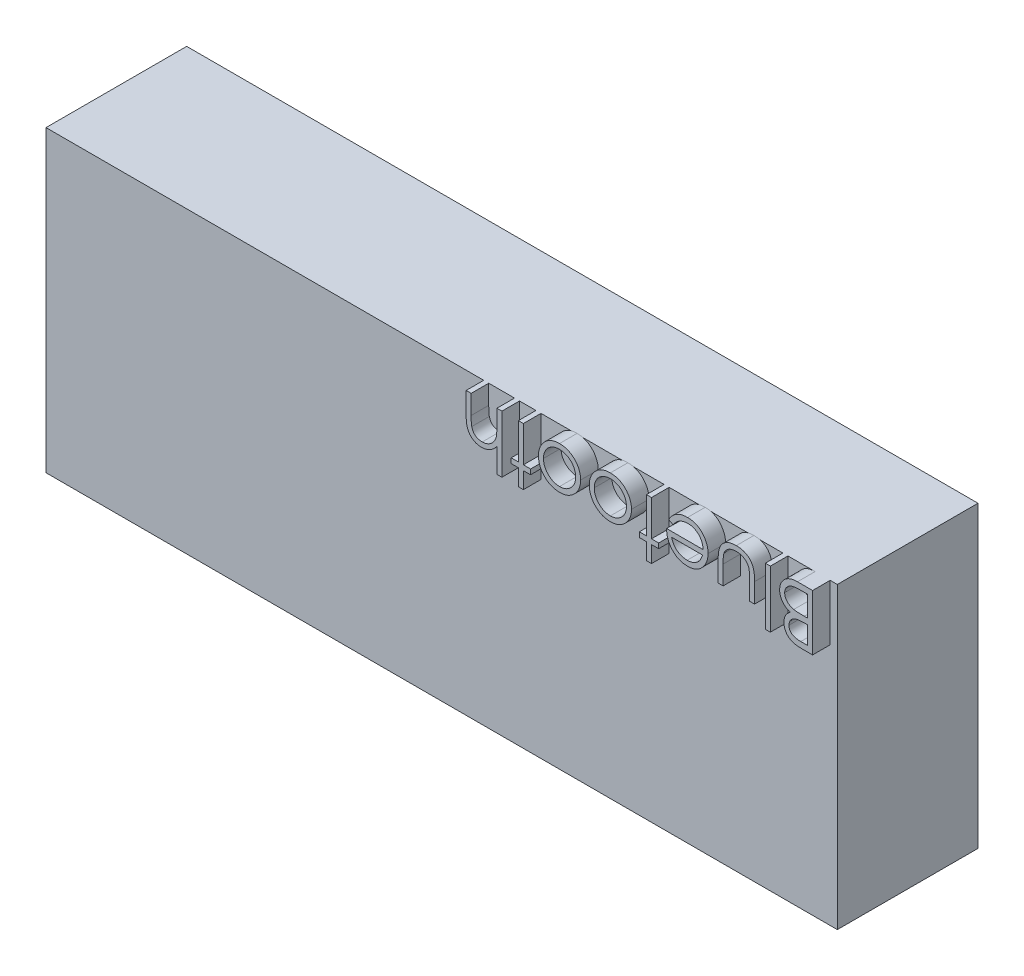
from build123d import *

# Parameters (mm, degrees)
SKETCH1_W           = 45
SKETCH1_H           = 17
BOSS_EXTRUDE1_DEPTH = 8
SKETCH2_W           = 0.284935898
SKETCH2_H           = 3.256410256
BOSS_EXTRUDE2_DEPTH = 1


with BuildPart() as part:
    # Sketch1 → Boss-Extrude1 (new body)
    with BuildSketch(Plane.XY):
        with Locations((-22.5, 8.5)):
            Rectangle(SKETCH1_W, SKETCH1_H)
    extrude(amount=BOSS_EXTRUDE1_DEPTH)

    # Sketch2 → Boss-Extrude2 (add)
    with BuildSketch(Plane.XY.offset(8)):
        with BuildLine():
            Line((-0.407051282, 13.825), (-1.026532452, 13.825))
            add(Edge.make_bspline(
                [(-1.026532452, 13.825), (-1.056857335, 13.825156921), (-1.115634507, 13.825461072), (-1.201098501, 13.830287737), (-1.281175294, 13.836704332), (-1.35572338, 13.847467824), (-1.425227832, 13.858628146), (-1.488983034, 13.875008826), (-1.547523015, 13.893101885), (-1.617817551, 13.92094051), (-1.697576333, 13.964174247), (-1.7833021, 14.028293986), (-1.857820167, 14.105168377), (-1.921182613, 14.192772808), (-1.972032324, 14.28914761), (-2.008354446, 14.392219247), (-2.03168916, 14.500253662), (-2.034058822, 14.574321243), (-2.03525641, 14.611753806)],
                knots=[0, 0, 0, 0, 9.0959e-05, 0.000176302, 0.000256745, 0.000331852, 0.000402223, 0.000467782, 0.000529134, 0.000585943, 0.000694367, 0.0008002, 0.000905896, 0.001014288, 0.001123535, 0.001231562, 0.00134133, 0.001453488, 0.001453488, 0.001453488, 0.001453488], degree=3))
            add(Edge.make_bspline(
                [(-2.03525641, 14.611753806), (-2.034278203, 14.646821674), (-2.032355933, 14.715733341), (-2.013576913, 14.816186738), (-1.985230438, 14.912110727), (-1.944324752, 15.002580893), (-1.892166566, 15.086802276), (-1.828708295, 15.163338275), (-1.753464177, 15.230686236), (-1.696970478, 15.268166335), (-1.668274239, 15.287204527)],
                knots=[0, 0, 0, 0, 0.000105099, 0.000206529, 0.000305524, 0.000404587, 0.000503422, 0.000601875, 0.000701862, 0.000805081, 0.000805081, 0.000805081, 0.000805081], degree=3))
            add(Edge.make_bspline(
                [(-1.668274239, 15.287204527), (-1.704345186, 15.301045853), (-1.773357845, 15.327527739), (-1.868451073, 15.37452874), (-1.950407983, 15.425257679), (-2.020284774, 15.480086384), (-2.078836588, 15.540805168), (-2.130996895, 15.605814962), (-2.175263744, 15.677379834), (-2.213033242, 15.753949009), (-2.242952687, 15.835117005), (-2.263720941, 15.920276589), (-2.276892235, 16.00846321), (-2.278614621, 16.068399436), (-2.279487179, 16.098763021)],
                knots=[0, 0, 0, 0, 0.000115862, 0.000221672, 0.000317675, 0.000404589, 0.000487344, 0.000570185, 0.000654188, 0.000739236, 0.000825961, 0.000913116, 0.001001804, 0.001092863, 0.001092863, 0.001092863, 0.001092863], degree=3))
            add(Edge.make_bspline(
                [(-2.279487179, 16.098763021), (-2.278600956, 16.129757203), (-2.276857285, 16.190739126), (-2.26399524, 16.280324877), (-2.242211085, 16.365933729), (-2.212227258, 16.448135531), (-2.17314183, 16.526448851), (-2.12592257, 16.601489144), (-2.0692495, 16.672144303), (-2.005430049, 16.73943962), (-1.934225902, 16.80097828), (-1.855764504, 16.853862582), (-1.772056737, 16.899540927), (-1.681956325, 16.936263754), (-1.586102591, 16.965011011), (-1.484473079, 16.984886817), (-1.3771255, 16.998332925), (-1.303455585, 16.999434879), (-1.26567508, 17)],
                knots=[0, 0, 0, 0, 9.2965e-05, 0.000182912, 0.000270839, 0.000357564, 0.000444886, 0.000532935, 0.000623027, 0.000716149, 0.000810866, 0.000904715, 0.000999484, 0.001096453, 0.001196056, 0.001299211, 0.001406816, 0.001520092, 0.001520092, 0.001520092, 0.001520092], degree=3))
            Line((-1.26567508, 17), (-0.407051282, 17))
            Line((-0.407051282, 17), (-0.407051282, 13.825))
        make_face()
        with BuildLine():
            Line((-0.691987179, 14.150641026), (-0.691987179, 15.168269231))
            Line((-0.691987179, 15.168269231), (-0.883428486, 15.168269231))
            add(Edge.make_bspline(
                [(-0.883428486, 15.168269231), (-0.911413002, 15.167909462), (-0.965484791, 15.167214317), (-1.043997361, 15.165160292), (-1.11669336, 15.159660798), (-1.18382327, 15.153844164), (-1.244937207, 15.144887778), (-1.300239597, 15.13392756), (-1.350227775, 15.122437825), (-1.407847206, 15.102841292), (-1.473197521, 15.074182831), (-1.542375043, 15.028618136), (-1.604637922, 14.975864071), (-1.656001204, 14.913289506), (-1.698763, 14.845714635), (-1.727552857, 14.772635549), (-1.747626216, 14.696570575), (-1.749413214, 14.644112234), (-1.750320513, 14.617477965)],
                knots=[0, 0, 0, 0, 8.3964e-05, 0.000162235, 0.000235554, 0.000302638, 0.000364342, 0.000420722, 0.000471782, 0.000518041, 0.000603156, 0.000685012, 0.000765726, 0.000846997, 0.000926956, 0.001004553, 0.001081836, 0.001161544, 0.001161544, 0.001161544, 0.001161544], degree=3))
            add(Edge.make_bspline(
                [(-1.750320513, 14.617477965), (-1.749878009, 14.599845497), (-1.749009988, 14.565257486), (-1.740826818, 14.514864741), (-1.72953414, 14.466910763), (-1.710909702, 14.422688306), (-1.688844556, 14.380644538), (-1.66056231, 14.342107543), (-1.627950279, 14.306033348), (-1.589928737, 14.273388889), (-1.54665311, 14.24386386), (-1.496752527, 14.219285683), (-1.441583665, 14.197443357), (-1.379996079, 14.180886362), (-1.313216539, 14.166512255), (-1.240226225, 14.157448022), (-1.161465028, 14.151625016), (-1.106894398, 14.150976338), (-1.078685897, 14.150641026)],
                knots=[0, 0, 0, 0, 5.2851e-05, 0.000103672, 0.000152881, 0.000200242, 0.000247195, 0.000295032, 0.000343206, 0.000392807, 0.000445022, 0.000499919, 0.000559328, 0.000622755, 0.000690987, 0.000764118, 0.000843191, 0.000927803, 0.000927803, 0.000927803, 0.000927803], degree=3))
            Line((-1.078685897, 14.150641026), (-0.691987179, 14.150641026))
        make_face(mode=Mode.SUBTRACT)
        with BuildLine():
            Line((-0.691987179, 15.493910256), (-0.691987179, 16.674358974))
            Line((-0.691987179, 16.674358974), (-1.097766426, 16.674358974))
            add(Edge.make_bspline(
                [(-1.097766426, 16.674358974), (-1.126809263, 16.673977387), (-1.182785501, 16.673241928), (-1.263667057, 16.671496784), (-1.338233662, 16.665022306), (-1.40710616, 16.658814977), (-1.469965885, 16.648674015), (-1.527424255, 16.638854064), (-1.578168894, 16.624403522), (-1.637543053, 16.60451932), (-1.703952452, 16.57274173), (-1.77647465, 16.526010062), (-1.84035162, 16.469087446), (-1.894546754, 16.403544285), (-1.939607631, 16.333014359), (-1.97078086, 16.257358853), (-1.990979337, 16.179104783), (-1.993358237, 16.12559752), (-1.994551282, 16.098763021)],
                knots=[0, 0, 0, 0, 8.7144e-05, 0.000167958, 0.000242592, 0.000311637, 0.000375322, 0.000433575, 0.000486346, 0.000533411, 0.000621324, 0.000706353, 0.000791497, 0.000876839, 0.000960842, 0.001041518, 0.001121424, 0.001201814, 0.001201814, 0.001201814, 0.001201814], degree=3))
            add(Edge.make_bspline(
                [(-1.994551282, 16.098763021), (-1.994307745, 16.081984403), (-1.993824599, 16.048697807), (-1.986230025, 15.999825141), (-1.975690698, 15.952248989), (-1.960158691, 15.906615593), (-1.941369185, 15.862139153), (-1.916581041, 15.820266851), (-1.888620197, 15.77921625), (-1.845313079, 15.726707986), (-1.781463528, 15.666939881), (-1.690699138, 15.609154389), (-1.588073896, 15.561797377), (-1.513465598, 15.541777202), (-1.47492488, 15.531435296)],
                knots=[0, 0, 0, 0, 5.0282e-05, 9.9752e-05, 0.000148043, 0.000196314, 0.000244168, 0.000292605, 0.000342002, 0.000393062, 0.000496563, 0.000602763, 0.000714617, 0.000834141, 0.000834141, 0.000834141, 0.000834141], degree=3))
            add(Edge.make_bspline(
                [(-1.47492488, 15.531435296), (-1.459477072, 15.528300831), (-1.425983037, 15.521504664), (-1.371365883, 15.514335298), (-1.308803548, 15.507904144), (-1.238563435, 15.503271916), (-1.16036619, 15.498299301), (-1.074236934, 15.496434267), (-0.980114777, 15.494157894), (-0.914807331, 15.493994914), (-0.880884415, 15.493910256)],
                knots=[0, 0, 0, 0, 4.7275e-05, 0.000102503, 0.000165156, 0.000235937, 0.000313659, 0.000400195, 0.000494345, 0.00059611, 0.00059611, 0.00059611, 0.00059611], degree=3))
            Line((-0.880884415, 15.493910256), (-0.691987179, 15.493910256))
        make_face(mode=Mode.SUBTRACT)
        with Locations((-2.951121795, 15.371794872)):
            Rectangle(SKETCH2_W, SKETCH2_H)
        with BuildLine():
            Line((-3.704166667, 14.679807692), (-3.989102564, 14.679807692))
            Line((-3.989102564, 14.679807692), (-3.989102564, 15.755949519))
            add(Edge.make_bspline(
                [(-3.989102564, 15.755949519), (-3.989231292, 15.787538727), (-3.989477543, 15.847967403), (-3.991147539, 15.934921751), (-3.995075553, 16.014221197), (-3.999986665, 16.085911552), (-4.006302317, 16.149980685), (-4.013816508, 16.206204816), (-4.022215219, 16.25522154), (-4.030436396, 16.284743013), (-4.034259816, 16.298472556)],
                knots=[0, 0, 0, 0, 9.4769e-05, 0.000181288, 0.000260882, 0.000332932, 0.000396851, 0.000453969, 0.000503119, 0.000545851, 0.000545851, 0.000545851, 0.000545851], degree=3))
            add(Edge.make_bspline(
                [(-4.034259816, 16.298472556), (-4.040393462, 16.31572897), (-4.052533236, 16.34988304), (-4.074552169, 16.399222336), (-4.101794336, 16.444917315), (-4.131594817, 16.488745657), (-4.166005522, 16.529350994), (-4.204523306, 16.566998531), (-4.246464485, 16.602127441), (-4.307900009, 16.644495716), (-4.391883133, 16.6893331), (-4.501898386, 16.728560205), (-4.621403134, 16.751659143), (-4.704096103, 16.75437388), (-4.746599559, 16.755769231)],
                knots=[0, 0, 0, 0, 5.4937e-05, 0.000108733, 0.000161748, 0.000214322, 0.000267581, 0.000321101, 0.000375743, 0.000431495, 0.000544744, 0.000660216, 0.00078071, 0.000908143, 0.000908143, 0.000908143, 0.000908143], degree=3))
            add(Edge.make_bspline(
                [(-4.746599559, 16.755769231), (-4.789108401, 16.754379092), (-4.871146739, 16.751696245), (-4.989402837, 16.728908955), (-5.097702195, 16.691733369), (-5.194780318, 16.639112717), (-5.280027791, 16.574961308), (-5.351059294, 16.499654919), (-5.409667762, 16.415610109), (-5.435257675, 16.352904324), (-5.448127003, 16.321369191)],
                knots=[0, 0, 0, 0, 0.000127432, 0.000245933, 0.000359782, 0.000469627, 0.000575844, 0.000678419, 0.000779147, 0.000881052, 0.000881052, 0.000881052, 0.000881052], degree=3))
            add(Edge.make_bspline(
                [(-5.448127003, 16.321369191), (-5.451934583, 16.308700032), (-5.460352214, 16.280691616), (-5.469331583, 16.233170163), (-5.477755141, 16.176554224), (-5.483371043, 16.110249231), (-5.489780513, 16.034839887), (-5.49199372, 15.949936218), (-5.495154294, 15.856038678), (-5.495179262, 15.790298426), (-5.495192308, 15.755949519)],
                knots=[0, 0, 0, 0, 3.9663e-05, 8.7686e-05, 0.000144892, 0.000211343, 0.000287245, 0.000371895, 0.00046606, 0.000569097, 0.000569097, 0.000569097, 0.000569097], degree=3))
            Line((-5.495192308, 15.755949519), (-5.495192308, 14.679807692))
            Line((-5.495192308, 14.679807692), (-5.780128205, 14.679807692))
            Line((-5.780128205, 14.679807692), (-5.780128205, 15.809375))
            add(Edge.make_bspline(
                [(-5.780128205, 15.809375), (-5.779726086, 15.847753435), (-5.77894592, 15.922212849), (-5.773969544, 16.03042348), (-5.765312185, 16.131462913), (-5.752510961, 16.225021849), (-5.73698131, 16.311122661), (-5.717343925, 16.389792441), (-5.693771382, 16.4611406), (-5.667172133, 16.526208158), (-5.635826264, 16.585259918), (-5.602259332, 16.640993122), (-5.5645166, 16.693224037), (-5.52335272, 16.742430516), (-5.477576262, 16.787418474), (-5.429577707, 16.830494553), (-5.377013169, 16.869001248), (-5.321654085, 16.904989796), (-5.262104821, 16.936927143), (-5.198877564, 16.964561638), (-5.1320392, 16.988571347), (-5.061485337, 17.007124819), (-4.987257349, 17.022777708), (-4.909450013, 17.033196025), (-4.827915259, 17.039848013), (-4.772478131, 17.040414626), (-4.744055489, 17.040705128)],
                knots=[0, 0, 0, 0, 0.000115135, 0.000223378, 0.000324896, 0.000419252, 0.000506574, 0.00058725, 0.000662271, 0.000731841, 0.00079784, 0.000862633, 0.000926883, 0.000990973, 0.001054835, 0.001119274, 0.001184275, 0.001250081, 0.001317237, 0.001386724, 0.001456931, 0.001530062, 0.001605402, 0.001684376, 0.0017654, 0.001850648, 0.001850648, 0.001850648, 0.001850648], degree=3))
            add(Edge.make_bspline(
                [(-4.744055489, 17.040705128), (-4.715846358, 17.040397396), (-4.66041279, 17.039792675), (-4.579070286, 17.033307934), (-4.501094998, 17.022618124), (-4.426808574, 17.00725029), (-4.355911597, 16.988421801), (-4.288748267, 16.964730443), (-4.22523377, 16.936769016), (-4.165231449, 16.904959954), (-4.108940373, 16.869132243), (-4.056487066, 16.829699838), (-4.006936418, 16.787691574), (-3.961663891, 16.741674768), (-3.920337431, 16.691993945), (-3.882777873, 16.638872355), (-3.848342802, 16.582910383), (-3.817180717, 16.522980725), (-3.790409107, 16.457147813), (-3.766773347, 16.384306795), (-3.747441532, 16.303659536), (-3.731709442, 16.215274851), (-3.719053491, 16.119575779), (-3.710266777, 16.016008716), (-3.705353844, 15.904825939), (-3.704570924, 15.828036395), (-3.704166667, 15.788386418)],
                knots=[0, 0, 0, 0, 8.4612e-05, 0.00016627, 0.000244614, 0.000320578, 0.000393709, 0.000464515, 0.000534001, 0.000601719, 0.00066806, 0.000733951, 0.000798453, 0.000862767, 0.000927343, 0.000992111, 0.001057778, 0.001124342, 0.0011945, 0.001270729, 0.001353875, 0.001443074, 0.001539951, 0.00164337, 0.00175479, 0.00187374, 0.00187374, 0.00187374, 0.00187374], degree=3))
            Line((-3.704166667, 15.788386418), (-3.704166667, 14.679807692))
        make_face()
        with BuildLine():
            Line((-8.335647035, 16.267307692), (-8.588782051, 16.400235377))
            add(Edge.make_bspline(
                [(-8.588782051, 16.400235377), (-8.568596794, 16.4360047), (-8.529324276, 16.50559764), (-8.462111472, 16.601263475), (-8.390922351, 16.686518562), (-8.314342184, 16.76096267), (-8.233331645, 16.826344613), (-8.146684322, 16.8823673), (-8.055841973, 16.931008171), (-7.959486956, 16.970653133), (-7.857711206, 17.001858042), (-7.749887726, 17.024893049), (-7.635517564, 17.03825355), (-7.557196629, 17.03987491), (-7.517092348, 17.040705128)],
                knots=[0, 0, 0, 0, 0.000123153, 0.000239607, 0.000350195, 0.000455891, 0.000559491, 0.000661985, 0.000764982, 0.000868213, 0.000974034, 0.001083932, 0.00119856, 0.00131885, 0.00131885, 0.00131885, 0.00131885], degree=3))
            add(Edge.make_bspline(
                [(-7.517092348, 17.040705128), (-7.472513554, 17.039664476), (-7.385553242, 17.037634466), (-7.258970754, 17.020133446), (-7.139790866, 16.991583515), (-7.028020201, 16.951700508), (-6.923932762, 16.89960565), (-6.82732062, 16.836142669), (-6.737679663, 16.761635981), (-6.65781975, 16.67544629), (-6.585969033, 16.583192142), (-6.522410523, 16.487125936), (-6.46988904, 16.387288181), (-6.425059876, 16.285194676), (-6.391890275, 16.179486653), (-6.367126088, 16.071095454), (-6.353250588, 15.959624148), (-6.351089205, 15.884248679), (-6.35, 15.846264022)],
                knots=[0, 0, 0, 0, 0.000133686, 0.000260783, 0.000382495, 0.000500791, 0.000615988, 0.000730827, 0.00084687, 0.000964755, 0.001082568, 0.001197407, 0.001309796, 0.001420618, 0.001531448, 0.001641618, 0.001753797, 0.001867758, 0.001867758, 0.001867758, 0.001867758], degree=3))
            add(Edge.make_bspline(
                [(-6.35, 15.846264022), (-6.350960792, 15.810617998), (-6.352864956, 15.739972284), (-6.364867171, 15.635409969), (-6.386138122, 15.533784158), (-6.415326645, 15.435010409), (-6.453019561, 15.339254102), (-6.499131645, 15.246456958), (-6.553734731, 15.156717724), (-6.595892085, 15.100109167), (-6.617127404, 15.071594551)],
                knots=[0, 0, 0, 0, 0.000106944, 0.000211948, 0.00031523, 0.000418063, 0.00052058, 0.000623546, 0.000728589, 0.000835205, 0.000835205, 0.000835205, 0.000835205], degree=3))
            add(Edge.make_bspline(
                [(-6.617127404, 15.071594551), (-6.645841214, 15.037185118), (-6.702267021, 14.969566783), (-6.798693368, 14.881528728), (-6.90169924, 14.806219699), (-7.012320752, 14.744782444), (-7.130371569, 14.697527481), (-7.255242794, 14.663915651), (-7.387279567, 14.643000835), (-7.477792219, 14.640421744), (-7.524088542, 14.639102564)],
                knots=[0, 0, 0, 0, 0.000134322, 0.000263957, 0.000390539, 0.000516376, 0.000642513, 0.000771035, 0.000903626, 0.001042455, 0.001042455, 0.001042455, 0.001042455], degree=3))
            add(Edge.make_bspline(
                [(-7.524088542, 14.639102564), (-7.571668748, 14.640324728), (-7.665010266, 14.642722335), (-7.80107218, 14.665148858), (-7.930069624, 14.700281354), (-8.050938047, 14.751467733), (-8.165539855, 14.814916746), (-8.271237499, 14.895113327), (-8.370932449, 14.987938486), (-8.428900587, 15.059399396), (-8.458398438, 15.095763221)],
                knots=[0, 0, 0, 0, 0.00014264, 0.000279826, 0.000412535, 0.000542821, 0.000672674, 0.000804457, 0.000939887, 0.001080205, 0.001080205, 0.001080205, 0.001080205], degree=3))
            add(Edge.make_bspline(
                [(-8.458398438, 15.095763221), (-8.478470732, 15.123162184), (-8.518481712, 15.177777735), (-8.568598725, 15.266832999), (-8.612102933, 15.360006181), (-8.646876405, 15.458803379), (-8.675033666, 15.562053998), (-8.695405209, 15.670496164), (-8.707351935, 15.784097583), (-8.709700253, 15.861500958), (-8.710897436, 15.900961538)],
                knots=[0, 0, 0, 0, 0.000101812, 0.000202947, 0.000305961, 0.000409966, 0.000516734, 0.000626756, 0.00074061, 0.000859019, 0.000859019, 0.000859019, 0.000859019], degree=3))
            Line((-8.710897436, 15.900961538), (-6.634935897, 15.900961538))
            add(Edge.make_bspline(
                [(-6.634935897, 15.900961538), (-6.636333867, 15.931532056), (-6.639082917, 15.991647745), (-6.651868517, 16.079622886), (-6.672119645, 16.163386857), (-6.7002693, 16.242582757), (-6.735566064, 16.317470616), (-6.777444671, 16.38856655), (-6.827712278, 16.454790832), (-6.883687159, 16.517001647), (-6.946022844, 16.572382213), (-7.01157898, 16.621988814), (-7.081216005, 16.663336057), (-7.154231917, 16.697403005), (-7.231005382, 16.72362321), (-7.311428436, 16.741679334), (-7.395250899, 16.753741734), (-7.452387382, 16.755085251), (-7.481475361, 16.755769231)],
                knots=[0, 0, 0, 0, 9.1765e-05, 0.000180453, 0.000266221, 0.000349905, 0.000432131, 0.000514266, 0.000596948, 0.000681145, 0.000764916, 0.000846708, 0.000927425, 0.001007384, 0.001088038, 0.001170271, 0.001254372, 0.00134159, 0.00134159, 0.00134159, 0.00134159], degree=3))
            add(Edge.make_bspline(
                [(-7.481475361, 16.755769231), (-7.509917297, 16.755225918), (-7.566351554, 16.754147881), (-7.650567345, 16.743356941), (-7.733612708, 16.726538177), (-7.814410795, 16.702134251), (-7.891667654, 16.673273013), (-7.96381474, 16.639527447), (-8.030174581, 16.601491995), (-8.092078349, 16.557595385), (-8.151795797, 16.504281212), (-8.211225088, 16.437624734), (-8.274377402, 16.358320461), (-8.314455279, 16.298786914), (-8.335647035, 16.267307692)],
                knots=[0, 0, 0, 0, 8.5286e-05, 0.000169223, 0.000254293, 0.000339215, 0.000422141, 0.000501524, 0.000577888, 0.000651306, 0.000728791, 0.000817481, 0.000918897, 0.001032694, 0.001032694, 0.001032694, 0.001032694], degree=3))
        make_face()
        with BuildLine():
            add(Edge.make_bspline(
                [(-8.425961538, 15.616025641), (-8.415592413, 15.57820355), (-8.395687062, 15.505597423), (-8.353027356, 15.405325801), (-8.307211568, 15.315185011), (-8.250948518, 15.237454421), (-8.187275942, 15.168787191), (-8.113502336, 15.10914119), (-8.032064948, 15.054430391), (-7.941483254, 15.008822107), (-7.845258185, 14.971356255), (-7.745387568, 14.943803949), (-7.642702443, 14.927608633), (-7.573541716, 14.925234113), (-7.538716947, 14.924038462)],
                knots=[0, 0, 0, 0, 0.000117514, 0.000225588, 0.000326304, 0.000420202, 0.000512451, 0.000606427, 0.000704152, 0.000806268, 0.00090997, 0.001013503, 0.0011165, 0.001220964, 0.001220964, 0.001220964, 0.001220964], degree=3))
            add(Edge.make_bspline(
                [(-7.538716947, 14.924038462), (-7.51027716, 14.924589237), (-7.454057679, 14.925678006), (-7.371254335, 14.936142254), (-7.291383667, 14.953180142), (-7.214828573, 14.977557607), (-7.141416132, 15.008210793), (-7.070809516, 15.045101669), (-7.00385858, 15.089988283), (-6.962004771, 15.124248402), (-6.940860377, 15.14155649)],
                knots=[0, 0, 0, 0, 8.5286e-05, 0.000168592, 0.000249928, 0.000329985, 0.000409243, 0.000488334, 0.000568596, 0.000650543, 0.000650543, 0.000650543, 0.000650543], degree=3))
            add(Edge.make_bspline(
                [(-6.940860377, 15.14155649), (-6.925714812, 15.155247752), (-6.89506388, 15.182955528), (-6.854152021, 15.2307202), (-6.814688231, 15.282255483), (-6.779618904, 15.339810942), (-6.746290714, 15.40171753), (-6.715920093, 15.468426965), (-6.688305717, 15.540220828), (-6.672804094, 15.590273988), (-6.664828726, 15.616025641)],
                knots=[0, 0, 0, 0, 6.119e-05, 0.000123834, 0.000188326, 0.000255744, 0.000325743, 0.000399173, 0.000475476, 0.000556333, 0.000556333, 0.000556333, 0.000556333], degree=3))
            Line((-6.664828726, 15.616025641), (-8.425961538, 15.616025641))
        make_face(mode=Mode.SUBTRACT)
        Polygon((-9.565705128, 13.743589744), (-9.850641026, 13.743589744), (-9.850641026, 14.679807692), (-10.257692308, 14.679807692), (-10.257692308, 14.96474359), (-9.850641026, 14.96474359), (-9.850641026, 17), (-9.565705128, 17), (-9.565705128, 14.96474359), (-9.158653846, 14.96474359), (-9.158653846, 14.679807692), (-9.565705128, 14.679807692), align=None)
        with BuildLine():
            add(Edge.make_bspline(
                [(-11.907522035, 14.639102564), (-11.951058056, 14.640026845), (-12.036421554, 14.641839134), (-12.16141769, 14.66130409), (-12.280610571, 14.690821452), (-12.394511499, 14.73237098), (-12.502178284, 14.786885584), (-12.604572212, 14.852809962), (-12.701488133, 14.930590128), (-12.759563745, 14.990791444), (-12.789042468, 15.021349159)],
                knots=[0, 0, 0, 0, 0.000130509, 0.000255897, 0.000378531, 0.000498457, 0.000618774, 0.000739799, 0.000863267, 0.000990542, 0.000990542, 0.000990542, 0.000990542], degree=3))
            add(Edge.make_bspline(
                [(-12.789042468, 15.021349159), (-12.814426098, 15.050571846), (-12.864702114, 15.10845168), (-12.929168873, 15.202300701), (-12.984705574, 15.299492078), (-13.029212689, 15.401316438), (-13.064305532, 15.50688489), (-13.089220842, 15.616560286), (-13.104040776, 15.730100415), (-13.106039182, 15.80721104), (-13.107051282, 15.846264022)],
                knots=[0, 0, 0, 0, 0.000116043, 0.000229841, 0.000340916, 0.00045141, 0.000562633, 0.000674184, 0.000788337, 0.000905475, 0.000905475, 0.000905475, 0.000905475], degree=3))
            add(Edge.make_bspline(
                [(-13.107051282, 15.846264022), (-13.106161069, 15.885543361), (-13.104401966, 15.963161164), (-13.087761685, 16.077478731), (-13.061879916, 16.188326895), (-13.0248396, 16.295241555), (-12.977343336, 16.398549594), (-12.919385276, 16.497799511), (-12.850559185, 16.593188189), (-12.772540095, 16.683901539), (-12.68631886, 16.767519171), (-12.592761863, 16.84035323), (-12.493639834, 16.9030155), (-12.387599658, 16.952786766), (-12.276150785, 16.992905872), (-12.158584328, 17.020570578), (-12.035005168, 17.037446799), (-11.950614162, 17.039603741), (-11.907522035, 17.040705128)],
                knots=[0, 0, 0, 0, 0.000117773, 0.000232725, 0.000345804, 0.000458844, 0.000571541, 0.000686407, 0.000803078, 0.000923941, 0.00104494, 0.001162753, 0.001279048, 0.001395973, 0.001513456, 0.001633783, 0.001757643, 0.001886881, 0.001886881, 0.001886881, 0.001886881], degree=3))
            add(Edge.make_bspline(
                [(-11.907522035, 17.040705128), (-11.864220855, 17.039594628), (-11.779413307, 17.037419657), (-11.65536882, 17.020696113), (-11.537307372, 16.992610286), (-11.42533132, 16.953283431), (-11.319291574, 16.902606694), (-11.219803535, 16.840597043), (-11.126202409, 16.767482289), (-11.039954142, 16.683911533), (-10.9619423, 16.593185614), (-10.893114338, 16.497800179), (-10.835156764, 16.39854942), (-10.787660373, 16.295241601), (-10.750620091, 16.188326883), (-10.724738313, 16.077478734), (-10.708098034, 15.963161164), (-10.706338931, 15.88554336), (-10.705448718, 15.846264022)],
                knots=[0, 0, 0, 0, 0.000129874, 0.000254364, 0.000374691, 0.000493373, 0.000609724, 0.000726559, 0.000844372, 0.000965371, 0.001086234, 0.001202905, 0.001317771, 0.001430468, 0.001543508, 0.001656586, 0.001771539, 0.001889312, 0.001889312, 0.001889312, 0.001889312], degree=3))
            add(Edge.make_bspline(
                [(-10.705448718, 15.846264022), (-10.7064653, 15.807422432), (-10.708477958, 15.730522758), (-10.723318116, 15.617208642), (-10.747962328, 15.507868916), (-10.783541659, 15.402876953), (-10.827966154, 15.301297325), (-10.882943903, 15.203749592), (-10.94803427, 15.110310652), (-10.998114965, 15.052507573), (-11.023457532, 15.023257212)],
                knots=[0, 0, 0, 0, 0.000116502, 0.000230655, 0.000342206, 0.000452223, 0.000562716, 0.000674346, 0.000787621, 0.000903664, 0.000903664, 0.000903664, 0.000903664], degree=3))
            add(Edge.make_bspline(
                [(-11.023457532, 15.023257212), (-11.052894252, 14.992439641), (-11.110786742, 14.931831465), (-11.208150041, 14.854204762), (-11.310103506, 14.787391565), (-11.418464778, 14.732904397), (-11.532682416, 14.690896841), (-11.652761163, 14.661166323), (-11.77821226, 14.641925232), (-11.863989215, 14.64005283), (-11.907522035, 14.639102564)],
                knots=[0, 0, 0, 0, 0.000127724, 0.000251192, 0.000372563, 0.000492879, 0.000614219, 0.000736853, 0.000863499, 0.000994008, 0.000994008, 0.000994008, 0.000994008], degree=3))
        make_face()
        with BuildLine():
            add(Edge.make_bspline(
                [(-11.90625, 14.924038462), (-11.875463773, 14.924913531), (-11.81468606, 14.926641081), (-11.72522351, 14.939779369), (-11.639101069, 14.960598557), (-11.556144372, 14.990165792), (-11.476674191, 15.028390619), (-11.400603376, 15.075075672), (-11.328135193, 15.130469096), (-11.259830651, 15.19347184), (-11.196395433, 15.261897925), (-11.141627712, 15.335498379), (-11.09470862, 15.41222806), (-11.056371887, 15.49252065), (-11.02696017, 15.576596743), (-11.006121041, 15.663975295), (-10.992957819, 15.75491637), (-10.991251642, 15.816750073), (-10.990384615, 15.848172075)],
                knots=[0, 0, 0, 0, 9.233e-05, 0.000182276, 0.000270667, 0.000357773, 0.00044596, 0.000534752, 0.000625069, 0.00071915, 0.000813231, 0.000904564, 0.000993899, 0.001082659, 0.001170965, 0.001260591, 0.001351797, 0.001446033, 0.001446033, 0.001446033, 0.001446033], degree=3))
            add(Edge.make_bspline(
                [(-10.990384615, 15.848172075), (-10.991838388, 15.888770351), (-10.994723854, 15.969350337), (-11.018307378, 16.087988332), (-11.057480711, 16.20209826), (-11.111498113, 16.310306208), (-11.178022169, 16.410597681), (-11.255808409, 16.500780246), (-11.345932255, 16.577376102), (-11.445324817, 16.641794507), (-11.552577576, 16.692523941), (-11.665892393, 16.72890369), (-11.784237503, 16.752234334), (-11.865223222, 16.754580619), (-11.90625, 16.755769231)],
                knots=[0, 0, 0, 0, 0.000121719, 0.000241589, 0.000361264, 0.000482718, 0.000603375, 0.000721483, 0.000838759, 0.000956957, 0.001075879, 0.001193542, 0.001313293, 0.001436243, 0.001436243, 0.001436243, 0.001436243], degree=3))
            add(Edge.make_bspline(
                [(-11.90625, 16.755769231), (-11.947279137, 16.754587505), (-12.028269515, 16.75225481), (-12.146779287, 16.728785489), (-12.260404664, 16.692682133), (-12.367768939, 16.641737211), (-12.467206764, 16.577619587), (-12.556687063, 16.500343887), (-12.635143188, 16.410834754), (-12.701733115, 16.310439188), (-12.754880147, 16.201930038), (-12.794237701, 16.088009358), (-12.817764666, 15.969344982), (-12.820657766, 15.888768557), (-12.822115385, 15.848172075)],
                knots=[0, 0, 0, 0, 0.000122951, 0.000242701, 0.00036097, 0.000479891, 0.00059809, 0.000714883, 0.00083341, 0.000954067, 0.00107524, 0.001194914, 0.001314785, 0.001436504, 0.001436504, 0.001436504, 0.001436504], degree=3))
            add(Edge.make_bspline(
                [(-12.822115385, 15.848172075), (-12.821254853, 15.816747547), (-12.819561459, 15.754908874), (-12.806305268, 15.664003951), (-12.785793238, 15.576422722), (-12.755113446, 15.492859737), (-12.718112356, 15.411837189), (-12.670055767, 15.335728173), (-12.615543006, 15.261851237), (-12.551991502, 15.19351306), (-12.483694627, 15.130238908), (-12.410682031, 15.075277458), (-12.334575885, 15.02836396), (-12.25508059, 14.990161085), (-12.17231162, 14.960712362), (-12.086450651, 14.939688678), (-11.997384284, 14.926688984), (-11.936822388, 14.92492762), (-11.90625, 14.924038462)],
                knots=[0, 0, 0, 0, 9.4236e-05, 0.000185442, 0.000275068, 0.000363587, 0.000452076, 0.000541743, 0.000633075, 0.000727156, 0.000821237, 0.000912061, 0.001000853, 0.00108904, 0.001176146, 0.001263919, 0.001353866, 0.00144556, 0.00144556, 0.00144556, 0.00144556], degree=3))
        make_face(mode=Mode.SUBTRACT)
        with BuildLine():
            add(Edge.make_bspline(
                [(-14.797586138, 14.639102564), (-14.841122159, 14.640026845), (-14.926485657, 14.641839134), (-15.051481792, 14.66130409), (-15.170674674, 14.690821452), (-15.284575602, 14.73237098), (-15.392242386, 14.786885584), (-15.494636315, 14.852809962), (-15.591552236, 14.930590128), (-15.649627847, 14.990791444), (-15.679106571, 15.021349159)],
                knots=[0, 0, 0, 0, 0.000130509, 0.000255897, 0.000378531, 0.000498457, 0.000618774, 0.000739799, 0.000863267, 0.000990542, 0.000990542, 0.000990542, 0.000990542], degree=3))
            add(Edge.make_bspline(
                [(-15.679106571, 15.021349159), (-15.7044902, 15.050571846), (-15.754766217, 15.10845168), (-15.819232976, 15.202300701), (-15.874769677, 15.299492078), (-15.919276791, 15.401316438), (-15.954369634, 15.50688489), (-15.979284945, 15.616560286), (-15.994104878, 15.730100415), (-15.996103284, 15.80721104), (-15.997115385, 15.846264022)],
                knots=[0, 0, 0, 0, 0.000116043, 0.000229841, 0.000340916, 0.00045141, 0.000562633, 0.000674184, 0.000788337, 0.000905475, 0.000905475, 0.000905475, 0.000905475], degree=3))
            add(Edge.make_bspline(
                [(-15.997115385, 15.846264022), (-15.996225172, 15.885543361), (-15.994466069, 15.963161164), (-15.977825788, 16.077478731), (-15.951944019, 16.188326895), (-15.914903703, 16.295241555), (-15.867407439, 16.398549594), (-15.809449379, 16.497799511), (-15.740623287, 16.593188189), (-15.662604197, 16.683901539), (-15.576382963, 16.767519171), (-15.482825966, 16.84035323), (-15.383703936, 16.9030155), (-15.277663761, 16.952786766), (-15.166214887, 16.992905872), (-15.048648431, 17.020570578), (-14.925069271, 17.037446799), (-14.840678264, 17.039603741), (-14.797586138, 17.040705128)],
                knots=[0, 0, 0, 0, 0.000117773, 0.000232725, 0.000345804, 0.000458844, 0.000571541, 0.000686407, 0.000803078, 0.000923941, 0.00104494, 0.001162753, 0.001279048, 0.001395973, 0.001513456, 0.001633783, 0.001757643, 0.001886881, 0.001886881, 0.001886881, 0.001886881], degree=3))
            add(Edge.make_bspline(
                [(-14.797586138, 17.040705128), (-14.754284958, 17.039594628), (-14.66947741, 17.037419657), (-14.545432922, 17.020696113), (-14.427371475, 16.992610286), (-14.315395422, 16.953283431), (-14.209355676, 16.902606694), (-14.109867637, 16.840597043), (-14.016266511, 16.767482289), (-13.930018245, 16.683911533), (-13.852006403, 16.593185614), (-13.783178441, 16.497800179), (-13.725220867, 16.39854942), (-13.677724476, 16.295241601), (-13.640684194, 16.188326883), (-13.614802415, 16.077478734), (-13.598162137, 15.963161164), (-13.596403034, 15.88554336), (-13.595512821, 15.846264022)],
                knots=[0, 0, 0, 0, 0.000129874, 0.000254364, 0.000374691, 0.000493373, 0.000609724, 0.000726559, 0.000844372, 0.000965371, 0.001086234, 0.001202905, 0.001317771, 0.001430468, 0.001543508, 0.001656586, 0.001771539, 0.001889312, 0.001889312, 0.001889312, 0.001889312], degree=3))
            add(Edge.make_bspline(
                [(-13.595512821, 15.846264022), (-13.596529403, 15.807422432), (-13.59854206, 15.730522758), (-13.613382219, 15.617208642), (-13.638026431, 15.507868916), (-13.673605761, 15.402876953), (-13.718030257, 15.301297325), (-13.773008005, 15.203749592), (-13.838098372, 15.110310652), (-13.888179067, 15.052507573), (-13.913521635, 15.023257212)],
                knots=[0, 0, 0, 0, 0.000116502, 0.000230655, 0.000342206, 0.000452223, 0.000562716, 0.000674346, 0.000787621, 0.000903664, 0.000903664, 0.000903664, 0.000903664], degree=3))
            add(Edge.make_bspline(
                [(-13.913521635, 15.023257212), (-13.942958355, 14.992439641), (-14.000850845, 14.931831465), (-14.098214144, 14.854204762), (-14.200167609, 14.787391565), (-14.308528881, 14.732904397), (-14.422746519, 14.690896841), (-14.542825266, 14.661166323), (-14.668276362, 14.641925232), (-14.754053317, 14.64005283), (-14.797586138, 14.639102564)],
                knots=[0, 0, 0, 0, 0.000127724, 0.000251192, 0.000372563, 0.000492879, 0.000614219, 0.000736853, 0.000863499, 0.000994008, 0.000994008, 0.000994008, 0.000994008], degree=3))
        make_face()
        with BuildLine():
            add(Edge.make_bspline(
                [(-14.796314103, 14.924038462), (-14.765527875, 14.924913531), (-14.704750162, 14.926641081), (-14.615287613, 14.939779369), (-14.529165172, 14.960598557), (-14.446208475, 14.990165792), (-14.366738294, 15.028390619), (-14.290667479, 15.075075672), (-14.218199295, 15.130469096), (-14.149894753, 15.19347184), (-14.086459535, 15.261897925), (-14.031691815, 15.335498379), (-13.984772723, 15.41222806), (-13.946435989, 15.49252065), (-13.917024272, 15.576596743), (-13.896185144, 15.663975295), (-13.883021921, 15.75491637), (-13.881315745, 15.816750073), (-13.880448718, 15.848172075)],
                knots=[0, 0, 0, 0, 9.233e-05, 0.000182276, 0.000270667, 0.000357773, 0.00044596, 0.000534752, 0.000625069, 0.00071915, 0.000813231, 0.000904564, 0.000993899, 0.001082659, 0.001170965, 0.001260591, 0.001351797, 0.001446033, 0.001446033, 0.001446033, 0.001446033], degree=3))
            add(Edge.make_bspline(
                [(-13.880448718, 15.848172075), (-13.88190249, 15.888770351), (-13.884787956, 15.969350337), (-13.908371481, 16.087988332), (-13.947544814, 16.20209826), (-14.001562216, 16.310306208), (-14.068086272, 16.410597681), (-14.145872512, 16.500780246), (-14.235996358, 16.577376102), (-14.335388919, 16.641794507), (-14.442641678, 16.692523941), (-14.555956495, 16.72890369), (-14.674301606, 16.752234334), (-14.755287325, 16.754580619), (-14.796314103, 16.755769231)],
                knots=[0, 0, 0, 0, 0.000121719, 0.000241589, 0.000361264, 0.000482718, 0.000603375, 0.000721483, 0.000838759, 0.000956957, 0.001075879, 0.001193542, 0.001313293, 0.001436243, 0.001436243, 0.001436243, 0.001436243], degree=3))
            add(Edge.make_bspline(
                [(-14.796314103, 16.755769231), (-14.83734324, 16.754587505), (-14.918333618, 16.75225481), (-15.03684339, 16.728785489), (-15.150468767, 16.692682133), (-15.257833041, 16.641737211), (-15.357270866, 16.577619587), (-15.446751166, 16.500343887), (-15.525207291, 16.410834754), (-15.591797218, 16.310439188), (-15.64494425, 16.201930038), (-15.684301804, 16.088009358), (-15.707828768, 15.969344982), (-15.710721869, 15.888768557), (-15.712179487, 15.848172075)],
                knots=[0, 0, 0, 0, 0.000122951, 0.000242701, 0.00036097, 0.000479891, 0.00059809, 0.000714883, 0.00083341, 0.000954067, 0.00107524, 0.001194914, 0.001314785, 0.001436504, 0.001436504, 0.001436504, 0.001436504], degree=3))
            add(Edge.make_bspline(
                [(-15.712179487, 15.848172075), (-15.711318956, 15.816747547), (-15.709625561, 15.754908874), (-15.69636937, 15.664003951), (-15.675857341, 15.576422722), (-15.645177548, 15.492859737), (-15.608176459, 15.411837189), (-15.56011987, 15.335728173), (-15.505607108, 15.261851237), (-15.442055605, 15.19351306), (-15.37375873, 15.130238908), (-15.300746134, 15.075277458), (-15.224639988, 15.02836396), (-15.145144693, 14.990161085), (-15.062375723, 14.960712362), (-14.976514754, 14.939688678), (-14.887448387, 14.926688984), (-14.826886491, 14.92492762), (-14.796314103, 14.924038462)],
                knots=[0, 0, 0, 0, 9.4236e-05, 0.000185442, 0.000275068, 0.000363587, 0.000452076, 0.000541743, 0.000633075, 0.000727156, 0.000821237, 0.000912061, 0.001000853, 0.00108904, 0.001176146, 0.001263919, 0.001353866, 0.00144556, 0.00144556, 0.00144556, 0.00144556], degree=3))
        make_face(mode=Mode.SUBTRACT)
        Polygon((-16.851923077, 13.743589744), (-17.136858974, 13.743589744), (-17.136858974, 14.679807692), (-17.543910256, 14.679807692), (-17.543910256, 14.96474359), (-17.136858974, 14.96474359), (-17.136858974, 17), (-16.851923077, 17), (-16.851923077, 14.96474359), (-16.444871795, 14.96474359), (-16.444871795, 14.679807692), (-16.851923077, 14.679807692), align=None)
        with BuildLine():
            Line((-18.073076923, 13.743589744), (-18.358012821, 13.743589744))
            Line((-18.358012821, 13.743589744), (-18.358012821, 15.118023838))
            add(Edge.make_bspline(
                [(-18.358012821, 15.118023838), (-18.388647931, 15.079846385), (-18.448201416, 15.005630876), (-18.547756599, 14.907750964), (-18.651493829, 14.824380555), (-18.760293456, 14.756300624), (-18.873693078, 14.703487133), (-18.991971346, 14.666538512), (-19.114826718, 14.643498173), (-19.198515637, 14.640578123), (-19.240805288, 14.639102564)],
                knots=[0, 0, 0, 0, 0.000146744, 0.000285264, 0.000417869, 0.000545289, 0.000669358, 0.000792061, 0.000916189, 0.001042986, 0.001042986, 0.001042986, 0.001042986], degree=3))
            add(Edge.make_bspline(
                [(-19.240805288, 14.639102564), (-19.283761425, 14.640596275), (-19.36787909, 14.643521292), (-19.489913213, 14.669294398), (-19.604686948, 14.710080783), (-19.710667146, 14.767403038), (-19.806217334, 14.838575871), (-19.889091669, 14.922049345), (-19.958614056, 15.016724035), (-20.005129685, 15.1049719), (-20.035616115, 15.183449775), (-20.054887382, 15.2507988), (-20.071235561, 15.32583759), (-20.085476791, 15.408537579), (-20.09496896, 15.499292673), (-20.102593087, 15.597694368), (-20.108014603, 15.703736739), (-20.108224699, 15.777142968), (-20.108333333, 15.815099159)],
                knots=[0, 0, 0, 0, 0.000128741, 0.000252104, 0.000372411, 0.000493068, 0.000612131, 0.000728612, 0.000844628, 0.000963265, 0.001026692, 0.001096933, 0.001173163, 0.001257021, 0.001348539, 0.001446782, 0.001553119, 0.001666973, 0.001666973, 0.001666973, 0.001666973], degree=3))
            Line((-20.108333333, 15.815099159), (-20.108333333, 17))
            Line((-20.108333333, 17), (-19.823397436, 17))
            Line((-19.823397436, 17), (-19.823397436, 15.90859375))
            add(Edge.make_bspline(
                [(-19.823397436, 15.90859375), (-19.823225494, 15.877004573), (-19.822896598, 15.816579855), (-19.821796036, 15.730069698), (-19.819395112, 15.65181524), (-19.815371897, 15.581654038), (-19.811323603, 15.519681175), (-19.805584177, 15.465795425), (-19.798956329, 15.42033483), (-19.792997122, 15.392971229), (-19.790324519, 15.380699119)],
                knots=[0, 0, 0, 0, 9.4769e-05, 0.000181277, 0.000259548, 0.000329614, 0.000392103, 0.000445834, 0.000492158, 0.000529829, 0.000529829, 0.000529829, 0.000529829], degree=3))
            add(Edge.make_bspline(
                [(-19.790324519, 15.380699119), (-19.78000921, 15.344664317), (-19.76023048, 15.275570641), (-19.713340084, 15.181884203), (-19.656137145, 15.101282233), (-19.585234715, 15.036054072), (-19.5029882, 14.984658281), (-19.408616777, 14.9496423), (-19.303326341, 14.927312227), (-19.229268498, 14.925162226), (-19.190559896, 14.924038462)],
                knots=[0, 0, 0, 0, 0.000112235, 0.000215201, 0.000312651, 0.000407163, 0.00050229, 0.000601745, 0.000707647, 0.000823614, 0.000823614, 0.000823614, 0.000823614], degree=3))
            add(Edge.make_bspline(
                [(-19.190559896, 14.924038462), (-19.167636378, 14.924463891), (-19.122271328, 14.925305804), (-19.055037611, 14.933972437), (-18.989615238, 14.947660215), (-18.926179802, 14.967878282), (-18.864601903, 14.992459628), (-18.804631232, 15.022625858), (-18.747088527, 15.059100076), (-18.691231076, 15.100151447), (-18.639233282, 15.145565114), (-18.590858644, 15.193506601), (-18.547734402, 15.244555575), (-18.508665084, 15.297895801), (-18.474939055, 15.354258182), (-18.445499477, 15.413099394), (-18.420520666, 15.474496766), (-18.408108509, 15.517109858), (-18.401898037, 15.53843149)],
                knots=[0, 0, 0, 0, 6.8737e-05, 0.000136029, 0.000203016, 0.000268997, 0.00033549, 0.000401764, 0.000470059, 0.000539641, 0.000609525, 0.000676984, 0.000743763, 0.00080979, 0.000875126, 0.000940547, 0.00100704, 0.001073628, 0.001073628, 0.001073628, 0.001073628], degree=3))
            add(Edge.make_bspline(
                [(-18.401898037, 15.53843149), (-18.398324414, 15.553871924), (-18.390537049, 15.587518531), (-18.382087164, 15.643012382), (-18.374523591, 15.707497876), (-18.36812955, 15.780877207), (-18.364207893, 15.863419262), (-18.359982203, 15.954560775), (-18.358409205, 16.054872651), (-18.358148897, 16.124627861), (-18.358012821, 16.161092748)],
                knots=[0, 0, 0, 0, 4.7531e-05, 0.000103577, 0.000168266, 0.000242318, 0.000324485, 0.000416151, 0.000516024, 0.000625421, 0.000625421, 0.000625421, 0.000625421], degree=3))
            Line((-18.358012821, 16.161092748), (-18.358012821, 17))
            Line((-18.358012821, 17), (-18.073076923, 17))
            Line((-18.073076923, 17), (-18.073076923, 13.743589744))
        make_face()
    extrude(amount=BOSS_EXTRUDE2_DEPTH)


solid = part.part
